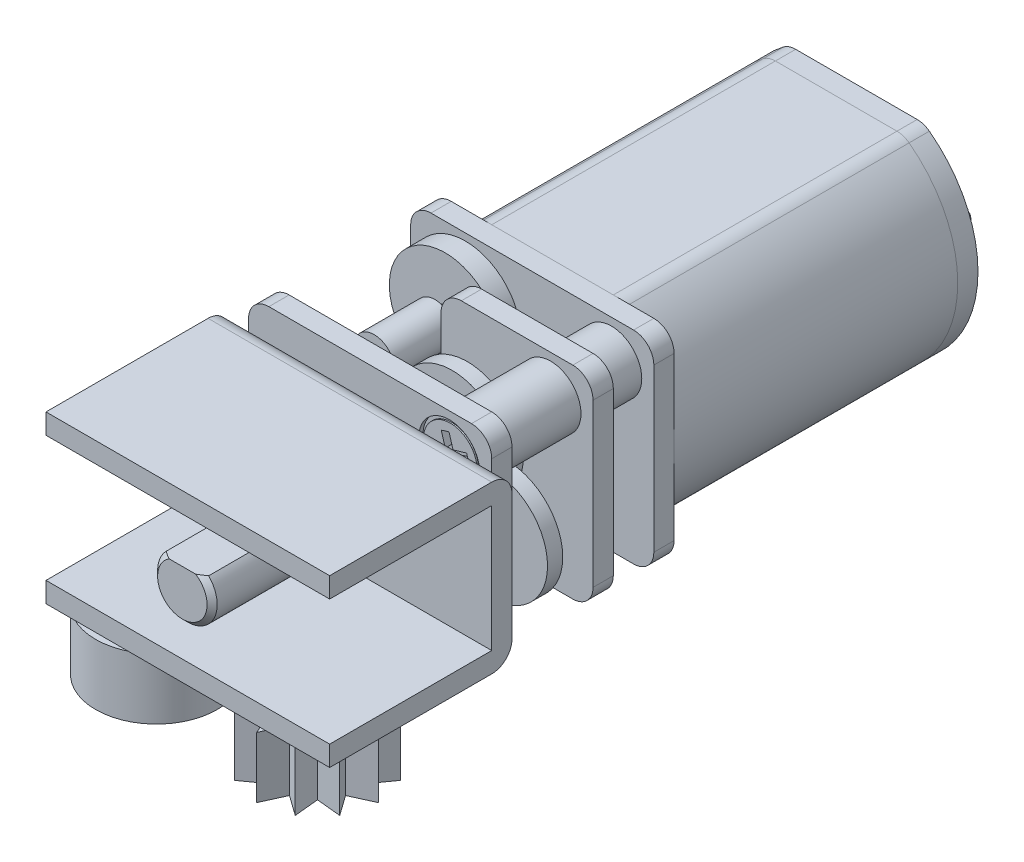
from build123d import *

# Parameters (mm, degrees)
BOSS_EXTRUDE1_DEPTH      = 7.5
FILLET3_R                = 1
BOSS_EXTRUDE2_DEPTH      = 1
BOSS_EXTRUDE3_START      = 9
BOSS_EXTRUDE3_DEPTH      = 1
SKETCH7_R                = 0.5
BOSS_EXTRUDE5_DEPTH      = 8
BOSS_EXTRUDE5_2_DEPTH    = 8
BOSS_EXTRUDE8_START      = 2
BOSS_EXTRUDE8_DEPTH      = 1
SKETCH5_R                = 0.75
SKETCH5_R_2              = 0.38
CUT_EXTRUDE1_DEPTH       = 9
SKETCH8_R                = 0.5
SKETCH8_R_2              = 0.38
CUT_EXTRUDE2_DEPTH       = 1
BOSS_EXTRUDE6_START      = 0.2
SKETCH9_R                = 2.75
SKETCH9_R_2              = 0.5
BOSS_EXTRUDE6_DEPTH      = 1
BOSS_EXTRUDE16_START     = 0.1
SKETCH9_3_R              = 1
SKETCH9_3_R_2            = 0.75
BOSS_EXTRUDE16_DEPTH     = 1.3
SKETCH6_R                = 1.95
SKETCH6_R_2              = 0.75
BOSS_EXTRUDE4_DEPTH      = 0.6
BOSS_EXTRUDE7_START      = 0.5
SKETCH10_R               = 1
SKETCH10_R_2             = 0.5
BOSS_EXTRUDE7_DEPTH      = 3
SKETCH12_R               = 1.5
SKETCH12_R_2             = 0.75
BOSS_EXTRUDE9_DEPTH      = 2
BOSS_EXTRUDE9_2_DEPTH    = 2
BOSS_EXTRUDE10_START     = 3
SKETCH12_2_R             = 1.5
SKETCH12_2_R_2           = 0.75
BOSS_EXTRUDE10_DEPTH     = 4
BOSS_EXTRUDE10_2_DEPTH   = 4
SKETCH13_R               = 1.5
CUT_EXTRUDE3_DEPTH       = 7.2
SKETCH14_R               = 1.5
CUT_EXTRUDE4_DEPTH       = 0.2
CHAMFER1_SIZE            = 0.5
BOSS_EXTRUDE11_START     = 0.2
SKETCH15_R               = 2.75
BOSS_EXTRUDE11_DEPTH     = 0.75
BOSS_EXTRUDE12_START     = 0.2
SKETCH16_R               = 1
BOSS_EXTRUDE12_DEPTH     = 1.15
BOSS_EXTRUDE13_START     = 0.4
SKETCH17_R               = 2.75
BOSS_EXTRUDE13_DEPTH     = 0.75
BOSS_EXTRUDE14_START     = 0.2
SKETCH18_R               = 1
BOSS_EXTRUDE14_DEPTH     = 1.5
SKETCH19_R               = 0.5
CUT_EXTRUDE5_DEPTH       = 23.8
SKETCH20_R               = 2.75
BOSS_EXTRUDE15_DEPTH     = 1
SKETCH21_R               = 0.5
CUT_EXTRUDE6_DEPTH       = 7.8
CHAMFER2_SIZE            = 0.25
CUT_EXTRUDE7_DEPTH       = 8.67
SKETCH24_R               = 0.8
CUT_EXTRUDE8_DEPTH       = 1
CUT_EXTRUDE9_DEPTH       = 1
BOSS_EXTRUDE17_DEPTH     = 1
SKETCH27_R               = 2.5
BOSS_EXTRUDE18_DEPTH     = 1.5
SKETCH28_W               = 0.3
SKETCH28_H               = 1.5
BOSS_EXTRUDE19_DEPTH     = 2
BOSS_EXTRUDE19_2_DEPTH   = 2
FILLET1_R                = 0.7
FILLET2_R                = 0.7
CUT_EXTRUDE10_DEPTH      = 0.4
EXTRUDE_THIN1_DEPTH      = 7
EXTRUDE_THIN1_DEPTH_BACK = 7
BOSS_EXTRUDE20_START     = 0.5
SKETCH32_R               = 3
BOSS_EXTRUDE20_DEPTH     = 3
BOSS_EXTRUDE20_2_DEPTH   = 3


with BuildPart() as part:
    # Sketch1 → Boss-Extrude1 (new body, symmetric)
    with BuildSketch(Plane.XY):
        with BuildLine():
            Line((3.31662479, 5), (-3.31662479, 5))
            ThreePointArc((-3.31662479, 5), (-6, 0), (-3.31662479, -5))
            Line((-3.31662479, -5), (3.31662479, -5))
            ThreePointArc((3.31662479, -5), (6, 0), (3.31662479, 5))
        make_face()
    extrude(amount=BOSS_EXTRUDE1_DEPTH, both=True)

    # Fillet3
    fillet3_edges = [part.edges().sort_by_distance(p)[0] for p in [
        (3.31662479, -5, 0),
        (-3.31662479, -5, 0),
        (-3.31662479, 5, 0),
        (3.31662479, 5, 0),
    ]]
    fillet(fillet3_edges, radius=FILLET3_R)

    # Sketch25 → Cut-Extrude9 (cut)
    with BuildSketch(Plane(origin=(0, 0, -7.5), x_dir=(-1, 0, 0), z_dir=(0, 0, -1))):
        with BuildLine():
            Line((-3, -5), (3, -5))
            ThreePointArc((3, -5), (3.316227766, -4.948683298), (3.6, -4.8))
            ThreePointArc((3.6, -4.8), (6, 0), (3.6, 4.8))
            ThreePointArc((3.6, 4.8), (3.316227766, 4.948683298), (3, 5))
            Line((3, 5), (-3, 5))
            ThreePointArc((-3, 5), (-3.316227766, 4.948683298), (-3.6, 4.8))
            ThreePointArc((-3.6, 4.8), (-6, 0), (-3.6, -4.8))
            ThreePointArc((-3.6, -4.8), (-3.316227766, -4.948683298), (-3, -5))
        make_face()
    extrude(amount=-CUT_EXTRUDE9_DEPTH, mode=Mode.SUBTRACT)


with BuildPart() as body_2:
    # Sketch2 → Boss-Extrude2 (new body)
    with BuildSketch(Plane.XY.offset(7.5)):
        with BuildLine():
            Line((-5, -5), (5, -5))
            ThreePointArc((5, -5), (5.707106781, -4.707106781), (6, -4))
            Line((6, -4), (6, 4))
            ThreePointArc((6, 4), (5.707106781, 4.707106781), (5, 5))
            Line((5, 5), (-5, 5))
            ThreePointArc((-5, 5), (-5.707106781, 4.707106781), (-6, 4))
            Line((-6, 4), (-6, -4))
            ThreePointArc((-6, -4), (-5.707106781, -4.707106781), (-5, -5))
        make_face()
    extrude(amount=BOSS_EXTRUDE2_DEPTH)


with BuildPart() as body_3:
    # Sketch2_2 → Boss-Extrude3 (new body)
    with BuildSketch(Plane.XY.offset(7.5).offset(BOSS_EXTRUDE3_START)):
        with BuildLine():
            Line((-5, -5), (5, -5))
            ThreePointArc((5, -5), (5.707106781, -4.707106781), (6, -4))
            Line((6, -4), (6, 4))
            ThreePointArc((6, 4), (5.707106781, 4.707106781), (5, 5))
            Line((5, 5), (-5, 5))
            ThreePointArc((-5, 5), (-5.707106781, 4.707106781), (-6, 4))
            Line((-6, 4), (-6, -4))
            ThreePointArc((-6, -4), (-5.707106781, -4.707106781), (-5, -5))
        make_face()
    extrude(amount=-BOSS_EXTRUDE3_DEPTH)


with BuildPart() as body_4:
    # Sketch7 → Boss-Extrude5 (new body)
    with BuildSketch(Plane.XY.offset(8.5)):
        with Locations((-3.104083332, 2.104083332)):
            Circle(SKETCH7_R)
    extrude(amount=BOSS_EXTRUDE5_DEPTH)


with BuildPart() as body_5:
    # Sketch7 → Boss-Extrude5 2 (new body)
    with BuildSketch(Plane.XY.offset(8.5)):
        with Locations((3.104083332, -2.104083332)):
            Circle(SKETCH7_R)
    extrude(amount=BOSS_EXTRUDE5_2_DEPTH)


with BuildPart() as body_6:
    # Sketch11 → Boss-Extrude8 (new body)
    with BuildSketch(Plane.XY.offset(8.5).offset(BOSS_EXTRUDE8_START)):
        with BuildLine():
            Line((-5, -1.25), (-2.5, -1.25))
            ThreePointArc((-2.5, -1.25), (-1.792893219, -0.957106781), (-1.5, -0.25))
            Line((-1.5, -0.25), (-1.5, 4))
            ThreePointArc((-1.5, 4), (-1.207106781, 4.707106781), (-0.5, 5))
            Line((-0.5, 5), (5, 5))
            ThreePointArc((5, 5), (5.707106781, 4.707106781), (6, 4))
            Line((6, 4), (6, -4))
            ThreePointArc((6, -4), (5.707106781, -4.707106781), (5, -5))
            Line((5, -5), (-5, -5))
            ThreePointArc((-5, -5), (-5.707106781, -4.707106781), (-6, -4))
            Line((-6, -4), (-6, -2.25))
            ThreePointArc((-6, -2.25), (-5.707106781, -1.542893219), (-5, -1.25))
        make_face()
    extrude(amount=BOSS_EXTRUDE8_DEPTH)


with BuildPart() as cut_extrude1_tool:
    # Sketch5 → Cut-Extrude1 (new body)
    with BuildSketch(Plane.XY.offset(16.5)):
        Circle(SKETCH5_R)
        with Locations((-3.104083332, 2.104083332)):
            Circle(SKETCH5_R_2)
        with Locations((3.104083332, -2.104083332)):
            Circle(SKETCH5_R_2)
        with Locations((3.904344047, 3.123475238)):
            Circle(SKETCH5_R)
        with Locations((-3.904344047, -3.123475238)):
            Circle(SKETCH5_R)
    extrude(amount=-CUT_EXTRUDE1_DEPTH)


with BuildPart() as body_2_1:
    add(body_2.part)

    # Cut-Extrude1: cut by cut_extrude1_tool
    add(cut_extrude1_tool.part, mode=Mode.SUBTRACT)


with BuildPart() as body_3_1:
    add(body_3.part)

    # Cut-Extrude1: cut by cut_extrude1_tool
    add(cut_extrude1_tool.part, mode=Mode.SUBTRACT)

    # Sketch6 → Boss-Extrude4 (add)
    with BuildSketch(Plane.XY.offset(16.5)):
        Circle(SKETCH6_R)
        Circle(SKETCH6_R_2, mode=Mode.SUBTRACT)
    extrude(amount=BOSS_EXTRUDE4_DEPTH)

    # Sketch13 → Cut-Extrude3 (cut)
    with BuildSketch(Plane.XY.offset(17.1)):
        Circle(SKETCH13_R)
    extrude(amount=-CUT_EXTRUDE3_DEPTH, mode=Mode.SUBTRACT)

    # Sketch14 → Cut-Extrude4 (cut)
    with BuildSketch(Plane.XY.offset(16.5)):
        with Locations((3.904344047, 3.123475238)):
            Circle(SKETCH14_R)
        with Locations((-3.904344047, -3.123475238)):
            Circle(SKETCH14_R)
    extrude(amount=-CUT_EXTRUDE4_DEPTH, mode=Mode.SUBTRACT)

    # Chamfer1
    chamfer1_edges = [body_3_1.edges().sort_by_distance(p)[0] for p in [
        (3.154344047, 3.123475238, 16.3),
        (-4.654344047, -3.123475238, 16.3),
    ]]
    chamfer(chamfer1_edges, length=CHAMFER1_SIZE)

    # Sketch24 → Cut-Extrude8 (cut)
    with BuildSketch(Plane.XY.offset(16.5)):
        with Locations((4.5, 0)):
            Circle(SKETCH24_R)
        with Locations((-4.5, 0)):
            Circle(SKETCH24_R)
    extrude(amount=-CUT_EXTRUDE8_DEPTH, mode=Mode.SUBTRACT)



with BuildPart() as body_6_1:
    add(body_6.part)

    # Cut-Extrude1: cut by cut_extrude1_tool
    add(cut_extrude1_tool.part, mode=Mode.SUBTRACT)


with BuildPart() as cut_extrude2_tool:
    # Sketch8 → Cut-Extrude2 (new body)
    with BuildSketch(Plane.XY.offset(16.5)):
        with Locations((-3.104083332, 2.104083332)):
            Circle(SKETCH8_R)
        with Locations((-3.104083332, 2.104083332)):
            Circle(SKETCH8_R_2, mode=Mode.SUBTRACT)
        with Locations((3.104083332, -2.104083332)):
            Circle(SKETCH8_R)
        with Locations((3.104083332, -2.104083332)):
            Circle(SKETCH8_R_2, mode=Mode.SUBTRACT)
    extrude(amount=-CUT_EXTRUDE2_DEPTH)


with BuildPart() as body_4_1:
    add(body_4.part)

    # Cut-Extrude2: cut by cut_extrude2_tool
    add(cut_extrude2_tool.part, mode=Mode.SUBTRACT)


with BuildPart() as body_5_1:
    add(body_5.part)

    # Cut-Extrude2: cut by cut_extrude2_tool
    add(cut_extrude2_tool.part, mode=Mode.SUBTRACT)


with BuildPart() as body_7:
    # Sketch9 → Boss-Extrude6 (new body)
    with BuildSketch(Plane.XY.offset(8.5).offset(BOSS_EXTRUDE6_START)):
        with Locations((-3.104083332, 2.104083332)):
            Circle(SKETCH9_R)
        with Locations((-3.104083332, 2.104083332)):
            Circle(SKETCH9_R_2, mode=Mode.SUBTRACT)
    extrude(amount=BOSS_EXTRUDE6_DEPTH)


with BuildPart() as body_8:
    # Sketch9_3 → Boss-Extrude16 (new body)
    with BuildSketch(Plane.XY.offset(8.5).offset(BOSS_EXTRUDE16_START)):
        Circle(SKETCH9_3_R)
        Circle(SKETCH9_3_R_2, mode=Mode.SUBTRACT)
        Circle(SKETCH9_3_R_2)
    extrude(amount=BOSS_EXTRUDE16_DEPTH)


with BuildPart() as body_9:
    # Sketch10 → Boss-Extrude7 (new body)
    with BuildSketch(Plane.XY.offset(9.7).offset(BOSS_EXTRUDE7_START)):
        with Locations((-3.104083332, 2.104083332)):
            Circle(SKETCH10_R)
        with Locations((-3.104083332, 2.104083332)):
            Circle(SKETCH10_R_2, mode=Mode.SUBTRACT)
    extrude(amount=BOSS_EXTRUDE7_DEPTH)


with BuildPart() as body_10:
    # Sketch12 → Boss-Extrude9 (new body)
    with BuildSketch(Plane.XY.offset(8.5)):
        with Locations((-3.904344047, -3.123475238)):
            Circle(SKETCH12_R)
        with Locations((-3.904344047, -3.123475238)):
            Circle(SKETCH12_R_2, mode=Mode.SUBTRACT)
    extrude(amount=BOSS_EXTRUDE9_DEPTH)


with BuildPart() as body_11:
    # Sketch12 → Boss-Extrude9 2 (new body)
    with BuildSketch(Plane.XY.offset(8.5)):
        with Locations((3.904344047, 3.123475238)):
            Circle(SKETCH12_R)
        with Locations((3.904344047, 3.123475238)):
            Circle(SKETCH12_R_2, mode=Mode.SUBTRACT)
    extrude(amount=BOSS_EXTRUDE9_2_DEPTH)


with BuildPart() as body_12:
    # Sketch12_2 → Boss-Extrude10 (new body)
    with BuildSketch(Plane.XY.offset(8.5).offset(BOSS_EXTRUDE10_START)):
        with Locations((-3.904344047, -3.123475238)):
            Circle(SKETCH12_2_R)
        with Locations((-3.904344047, -3.123475238)):
            Circle(SKETCH12_2_R_2, mode=Mode.SUBTRACT)
    extrude(amount=BOSS_EXTRUDE10_DEPTH)


with BuildPart() as body_13:
    # Sketch12_2 → Boss-Extrude10 2 (new body)
    with BuildSketch(Plane.XY.offset(8.5).offset(BOSS_EXTRUDE10_START)):
        with Locations((3.904344047, 3.123475238)):
            Circle(SKETCH12_2_R)
        with Locations((3.904344047, 3.123475238)):
            Circle(SKETCH12_2_R_2, mode=Mode.SUBTRACT)
    extrude(amount=BOSS_EXTRUDE10_2_DEPTH)


with BuildPart() as body_14:
    # Sketch15 → Boss-Extrude11 (new body)
    with BuildSketch(Plane.XY.offset(11.5).offset(BOSS_EXTRUDE11_START)):
        Circle(SKETCH15_R)
    extrude(amount=BOSS_EXTRUDE11_DEPTH)


with BuildPart() as body_15:
    # Sketch16 → Boss-Extrude12 (new body)
    with BuildSketch(Plane.XY.offset(12.45).offset(BOSS_EXTRUDE12_START)):
        Circle(SKETCH16_R)
    extrude(amount=BOSS_EXTRUDE12_DEPTH)


with BuildPart() as body_16:
    # Sketch17 → Boss-Extrude13 (new body)
    with BuildSketch(Plane.XY.offset(12.45).offset(BOSS_EXTRUDE13_START)):
        with Locations((3.104083332, -2.104083332)):
            Circle(SKETCH17_R)
    extrude(amount=BOSS_EXTRUDE13_DEPTH)


with BuildPart() as body_17:
    # Sketch18 → Boss-Extrude14 (new body)
    with BuildSketch(Plane.XY.offset(13.6).offset(BOSS_EXTRUDE14_START)):
        with Locations((3.104083332, -2.104083332)):
            Circle(SKETCH18_R)
    extrude(amount=BOSS_EXTRUDE14_DEPTH)


with BuildPart() as cut_extrude5_tool:
    # Sketch19 → Cut-Extrude5 (new body, through all)
    with BuildSketch(Plane.XY.offset(15.3)):
        with Locations((3.104083332, -2.104083332)):
            Circle(SKETCH19_R)
    extrude(amount=-CUT_EXTRUDE5_DEPTH)


with BuildPart() as body_17_1:
    add(body_17.part)

    # Cut-Extrude5: cut by cut_extrude5_tool
    add(cut_extrude5_tool.part, mode=Mode.SUBTRACT)


with BuildPart() as body_16_1:
    add(body_16.part)

    # Cut-Extrude5: cut by cut_extrude5_tool
    add(cut_extrude5_tool.part, mode=Mode.SUBTRACT)


with BuildPart() as body_6_2:
    add(body_6_1.part)

    # Cut-Extrude5: cut by cut_extrude5_tool
    add(cut_extrude5_tool.part, mode=Mode.SUBTRACT)


with BuildPart() as body_18:
    # Sketch20 → Boss-Extrude15 (new body)
    with BuildSketch(Plane.XY.offset(15.3)):
        Circle(SKETCH20_R)
    extrude(amount=-BOSS_EXTRUDE15_DEPTH)


with BuildPart() as cut_extrude6_tool:
    # Sketch21 → Cut-Extrude6 (new body)
    with BuildSketch(Plane.XY.offset(15.3)):
        Circle(SKETCH21_R)
    extrude(amount=-CUT_EXTRUDE6_DEPTH)


with BuildPart() as body_8_1:
    add(body_8.part)

    # Cut-Extrude6: cut by cut_extrude6_tool
    add(cut_extrude6_tool.part, mode=Mode.SUBTRACT)


with BuildPart() as body_14_1:
    add(body_14.part)

    # Cut-Extrude6: cut by cut_extrude6_tool
    add(cut_extrude6_tool.part, mode=Mode.SUBTRACT)


with BuildPart() as body_15_1:
    add(body_15.part)

    # Cut-Extrude6: cut by cut_extrude6_tool
    add(cut_extrude6_tool.part, mode=Mode.SUBTRACT)


with BuildPart() as body_18_1:
    add(body_18.part)

    # Cut-Extrude6: cut by cut_extrude6_tool
    add(cut_extrude6_tool.part, mode=Mode.SUBTRACT)


with BuildPart() as body_19:
    # Sketch22 → Revolve1 (revolve)
    with BuildSketch(Plane(origin=(0, 0, 0), x_dir=(1, 0, 0), z_dir=(0, 1, 0))):
        Polygon((-0.5, -7.5), (-0.5, -15.3), (-1.47, -15.3), (-1.47, -25.77), (0, -25.77), (0, -7.5), align=None)
    revolve(axis=Axis((0, 0, 0), (0, 0, 1)))

    # Chamfer2
    chamfer2_edges = [body_19.edges().sort_by_distance(p)[0] for p in [
        (1.47, 0, 25.77),
    ]]
    chamfer(chamfer2_edges, length=CHAMFER2_SIZE)

    # Sketch23 → Cut-Extrude7 (cut)
    with BuildSketch(Plane.XY.offset(25.77)):
        with BuildLine():
            Line((1.048808848, 1.03), (-1.048808848, 1.03))
            ThreePointArc((-1.048808848, 1.03), (0, 1.47), (1.048808848, 1.03))
        make_face()
    extrude(amount=-CUT_EXTRUDE7_DEPTH, mode=Mode.SUBTRACT)


with BuildPart() as body_20:
    # Sketch26 → Boss-Extrude17 (new body)
    with BuildSketch(Plane(origin=(0, 0, -6.5), x_dir=(-1, 0, 0), z_dir=(0, 0, -1))):
        with BuildLine():
            Line((-3, -5), (3, -5))
            ThreePointArc((3, -5), (3.316227766, -4.948683298), (3.6, -4.8))
            ThreePointArc((3.6, -4.8), (6, 0), (3.6, 4.8))
            ThreePointArc((3.6, 4.8), (3.316227766, 4.948683298), (3, 5))
            Line((3, 5), (-3, 5))
            ThreePointArc((-3, 5), (-3.316227766, 4.948683298), (-3.6, 4.8))
            ThreePointArc((-3.6, 4.8), (-6, 0), (-3.6, -4.8))
            ThreePointArc((-3.6, -4.8), (-3.316227766, -4.948683298), (-3, -5))
        make_face()
    extrude(amount=BOSS_EXTRUDE17_DEPTH)

    # Sketch27 → Boss-Extrude18 (add)
    with BuildSketch(Plane(origin=(0, 0, -7.5), x_dir=(-1, 0, 0), z_dir=(0, 0, -1))):
        Circle(SKETCH27_R)
    extrude(amount=BOSS_EXTRUDE18_DEPTH)


with BuildPart() as body_21:
    # Sketch28 → Boss-Extrude19 (new body)
    with BuildSketch(Plane(origin=(0, 0, -7.5), x_dir=(-1, 0, 0), z_dir=(0, 0, -1))):
        with Locations((3.5, 0)):
            Rectangle(SKETCH28_W, SKETCH28_H)
    extrude(amount=BOSS_EXTRUDE19_DEPTH)

    # Fillet1
    fillet1_edges = [body_21.edges().sort_by_distance(p)[0] for p in [
        (-3.5, -0.75, -9.5),
        (-3.5, 0.75, -9.5),
    ]]
    fillet(fillet1_edges, radius=FILLET1_R)


with BuildPart() as body_22:
    # Sketch28 → Boss-Extrude19 2 (new body)
    with BuildSketch(Plane(origin=(0, 0, -7.5), x_dir=(-1, 0, 0), z_dir=(0, 0, -1))):
        with Locations((-3.5, 0)):
            Rectangle(SKETCH28_W, SKETCH28_H)
    extrude(amount=BOSS_EXTRUDE19_2_DEPTH)

    # Fillet2
    fillet2_edges = [body_22.edges().sort_by_distance(p)[0] for p in [
        (3.5, -0.75, -9.5),
        (3.5, 0.75, -9.5),
    ]]
    fillet(fillet2_edges, radius=FILLET2_R)


with BuildPart() as body_23:
    # Sketch29 → Revolve2 (revolve)
    with BuildSketch(Plane(origin=(0, 0, 0), x_dir=(0.780868809, 0.624695048, 0), z_dir=(0.624695048, -0.780868809, 0))):
        Polygon((5.7, 7.5), (5.7, 15.755), (6.325, 16.38), (6.325, 16.45), (5, 16.45), (5, 7.5), align=None)
    revolve(axis=Axis((3.904344047, 3.123475238, 16.5), (0, 0, 1)))


with BuildPart() as body_24:
    # Sketch29_3 → Revolve3 (revolve)
    with BuildSketch(Plane(origin=(0, 0, 0), x_dir=(0.780868809, 0.624695048, 0), z_dir=(0.624695048, -0.780868809, 0))):
        Polygon((-5.7, 7.5), (-5.7, 15.755), (-6.325, 16.38), (-6.325, 16.45), (-5, 16.45), (-5, 7.5), align=None)
    revolve(axis=Axis((-3.904344047, -3.123475238, 16.5), (0, 0, 1)))


with BuildPart() as cut_extrude10_tool:
    # Sketch30 → Cut-Extrude10 (new body)
    with BuildSketch(Plane.XY.offset(16.45)):
        Polygon((-3.774222132, -2.210749492), (-4.020996733, -2.865808494), (-4.676055735, -2.619033892), (-4.817069793, -2.993353322), (-4.162010791, -3.240127924), (-4.408785393, -3.895186926), (-4.034465963, -4.036200984), (-3.787691361, -3.381141982), (-3.132632359, -3.627916583), (-2.991618301, -3.253597153), (-3.646677303, -3.006822552), (-3.399902702, -2.35176355), align=None)
        Polygon((3.456494168, 3.929347737), (3.65569802, 3.258290493), (2.984640775, 3.059086641), (3.098471548, 2.675625358), (3.769528792, 2.87482921), (3.968732644, 2.203771966), (4.352193927, 2.317602738), (4.152990075, 2.988659983), (4.824047319, 3.187863835), (4.710216547, 3.571325117), (4.039159302, 3.372121265), (3.83995545, 4.04317851), align=None)
    extrude(amount=-CUT_EXTRUDE10_DEPTH)


with BuildPart() as body_23_1:
    add(body_23.part)

    # Cut-Extrude10: cut by cut_extrude10_tool
    add(cut_extrude10_tool.part, mode=Mode.SUBTRACT)


with BuildPart() as body_24_1:
    add(body_24.part)

    # Cut-Extrude10: cut by cut_extrude10_tool
    add(cut_extrude10_tool.part, mode=Mode.SUBTRACT)


with BuildPart() as body_3_2:
    add(body_3_1.part)

    add(body_4_1.part)  # Extrude-Thin1 merges body 4

    add(body_5_1.part)  # Extrude-Thin1 merges body 5

    add(body_19.part)  # Extrude-Thin1 merges body 19
    # Sketch31 → Extrude-Thin1 (add, two sides)
    with BuildSketch(Plane(origin=(0, 0, 0), x_dir=(0, 0, -1), z_dir=(1, 0, 0))) as extrude_thin1_sk:
        with BuildLine():
            Line((-25.5, 4), (-17.5, 4))
            ThreePointArc((-17.5, 4), (-16.792893219, 3.707106781), (-16.5, 3))
            Line((-16.5, 3), (-16.5, -3.2))
            ThreePointArc((-16.5, -3.2), (-16.792893219, -3.907106781), (-17.5, -4.2))
            Line((-17.5, -4.2), (-25.5, -4.2))
            Line((-25.5, -4.2), (-25.5, -3.2))
            Line((-25.5, -3.2), (-17.5, -3.2))
            Line((-17.5, -3.2), (-17.5, 3))
            Line((-17.5, 3), (-25.5, 3))
            Line((-25.5, 3), (-25.5, 4))
        make_face()
    extrude(amount=EXTRUDE_THIN1_DEPTH)
    extrude(extrude_thin1_sk.sketch, amount=-EXTRUDE_THIN1_DEPTH_BACK)


with BuildPart() as body_22_2:
    # Sketch32 → Boss-Extrude20 (new body)
    with BuildSketch(Plane.XZ.offset(4.2).offset(BOSS_EXTRUDE20_START)):
        with Locations((-4.75, 22.3)):
            Circle(SKETCH32_R)
    extrude(amount=BOSS_EXTRUDE20_DEPTH)


with BuildPart() as body_23_2:
    # Sketch32 → Boss-Extrude20 2 (new body)
    with BuildSketch(Plane.XZ.offset(4.2).offset(BOSS_EXTRUDE20_START)):
        Polygon((3.2, 25.3), (2.694063611, 24.188180308), (1.7, 24.898076211), (1.817756081, 23.682243919), (0.601923789, 23.8), (1.311819692, 22.805936389), (0.2, 22.3), (1.311819692, 21.794063611), (0.601923789, 20.8), (1.817756081, 20.917756081), (1.7, 19.701923789), (2.694063611, 20.411819692), (3.2, 19.3), (3.705936389, 20.411819692), (4.7, 19.701923789), (4.582243919, 20.917756081), (5.798076211, 20.8), (5.088180308, 21.794063611), (6.2, 22.3), (5.088180308, 22.805936389), (5.798076211, 23.8), (4.582243919, 23.682243919), (4.7, 24.898076211), (3.705936389, 24.188180308), align=None)
    extrude(amount=BOSS_EXTRUDE20_2_DEPTH)


solid = Compound([part.part, body_2_1.part, body_7.part, body_9.part, body_10.part, body_11.part, body_12.part, body_13.part, body_17_1.part, body_16_1.part, body_6_2.part, body_8_1.part, body_14_1.part, body_15_1.part, body_18_1.part, body_20.part, body_21.part, body_22.part, body_23_1.part, body_24_1.part, body_3_2.part, body_22_2.part, body_23_2.part])
